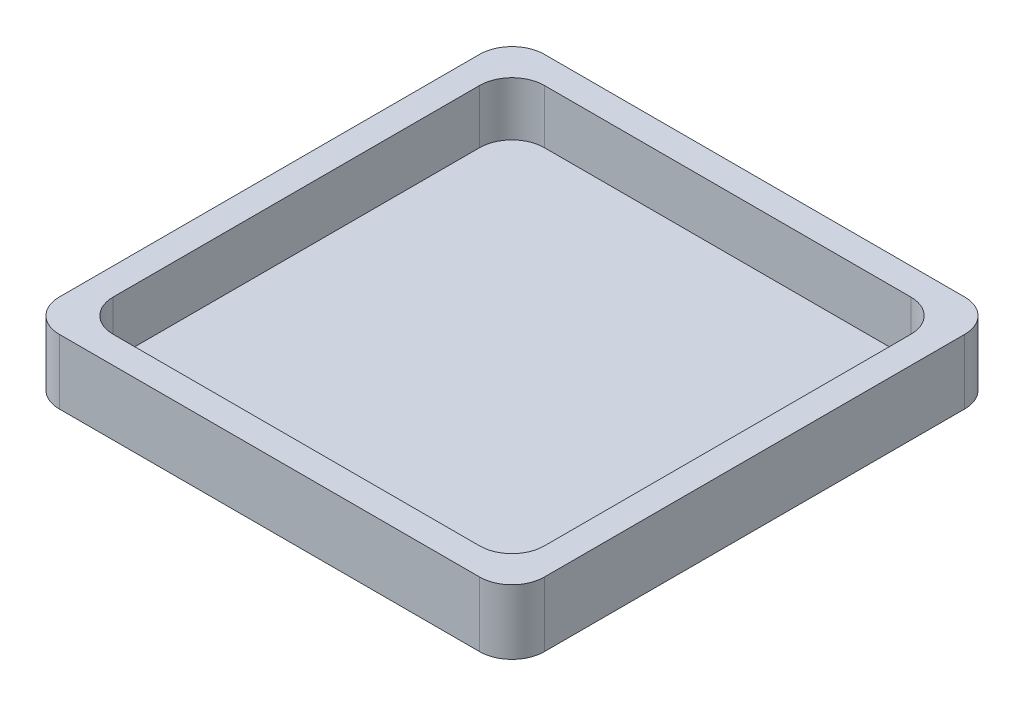
from build123d import *

# Parameters (mm, degrees)
SKETCH1_W           = 40
SKETCH1_H           = 40
BOSS_EXTRUDE1_DEPTH = 1
SKETCH1_3_W         = 45
SKETCH1_3_H         = 45
SKETCH1_3_W_2       = 40
SKETCH1_3_H_2       = 40
BOSS_EXTRUDE2_DEPTH = 6
FILLET1_R           = 3


with BuildPart() as part:
    # Sketch1 → Boss-Extrude1 (new body)
    with BuildSketch(Plane(origin=(0, 0, 0), x_dir=(1, 0, 0), z_dir=(0, 1, 0))):
        Rectangle(SKETCH1_W, SKETCH1_H)
    extrude(amount=BOSS_EXTRUDE1_DEPTH)

    # Sketch1_3 → Boss-Extrude2 (add)
    with BuildSketch(Plane(origin=(0, 0, 0), x_dir=(1, 0, 0), z_dir=(0, 1, 0))):
        Rectangle(SKETCH1_3_W, SKETCH1_3_H)
        Rectangle(SKETCH1_3_W_2, SKETCH1_3_H_2, mode=Mode.SUBTRACT)
    extrude(amount=BOSS_EXTRUDE2_DEPTH)

    # Fillet1
    fillet1_edges = [part.edges().sort_by_distance(p)[0] for p in [
        (22.5, 3, 22.5),
        (-20, 3.5, 20),
        (20, 3.5, 20),
        (20, 3.5, -20),
        (-20, 3.5, -20),
        (-22.5, 3, 22.5),
        (-22.5, 3, -22.5),
        (22.5, 3, -22.5),
    ]]
    fillet(fillet1_edges, radius=FILLET1_R)


solid = part.part
